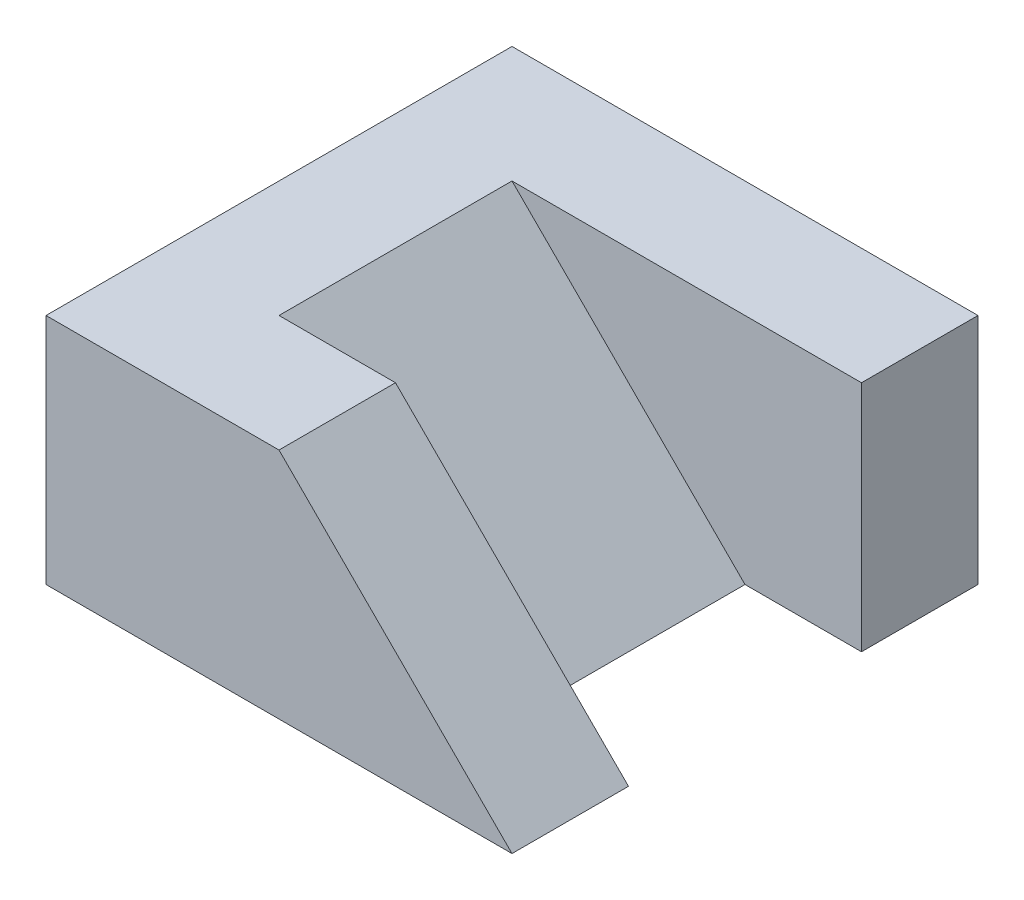
from build123d import *

# Parameters (mm, degrees)
EXTRUDE_1_DEPTH     = 10
CUT_EXTRUDE_START   = -5
CUT_EXTRUDE_1_DEPTH = 10
CUT_EXTRUDE_2_DEPTH = 5


with BuildPart() as part:
    # 草圖1 → 填料-伸長1 (new body)
    with BuildSketch(Plane(origin=(0, 0, 0), x_dir=(1, 0, 0), z_dir=(0, 1, 0))):
        Polygon((10, 5), (10, 10), (-10, 10), (-10, -10), (10, -10), (10, -5), (5, -5), (5, 5), align=None)
    extrude(amount=EXTRUDE_1_DEPTH)

    # 草圖2 → 除料-伸長1 (cut)
    with BuildSketch(Plane.XY.offset(10).offset(CUT_EXTRUDE_START)):
        Polygon((10, 0), (10, 10), (-5, 10), (5, 0), align=None)
    extrude(amount=-CUT_EXTRUDE_1_DEPTH, mode=Mode.SUBTRACT)

    # 草圖3 → 除料-伸長2 (cut)
    with BuildSketch(Plane.XY.offset(10)):
        Polygon((0, 10), (10, 0), (10, 10), align=None)
    extrude(amount=-CUT_EXTRUDE_2_DEPTH, mode=Mode.SUBTRACT)


solid = part.part
